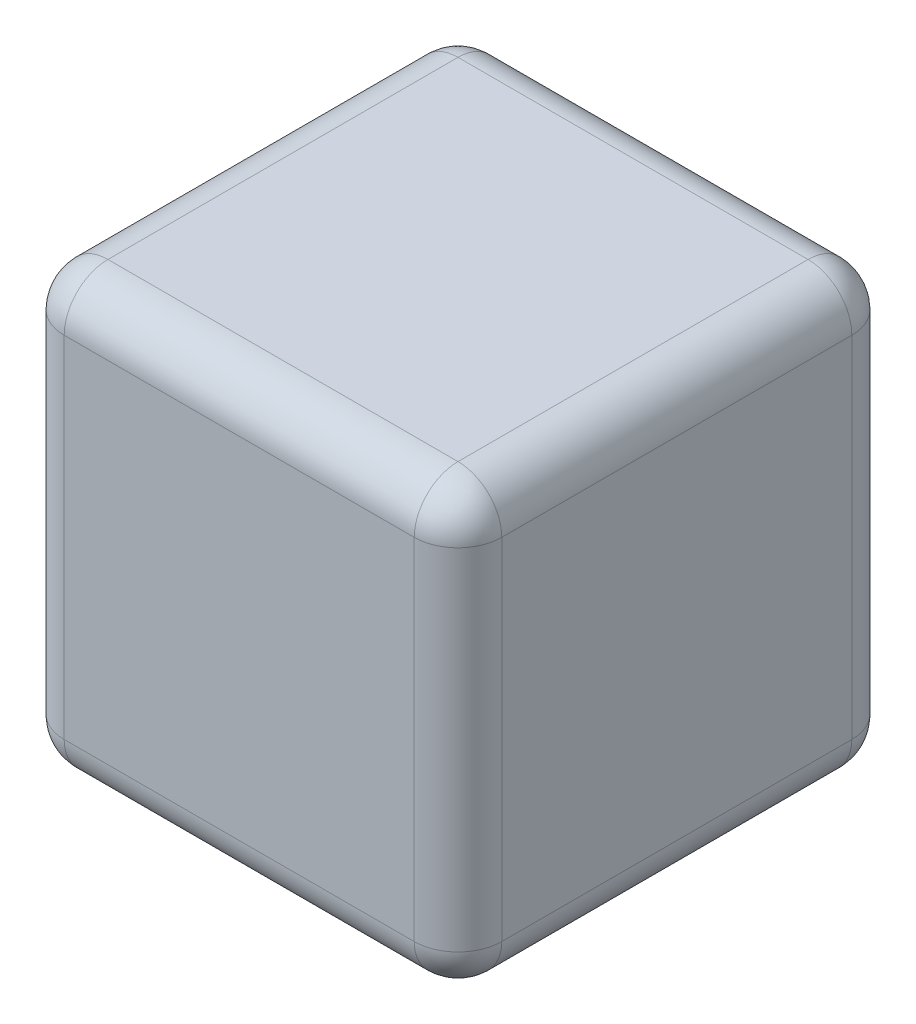
from build123d import *

# Parameters (mm, degrees)
SKETCH1_W           = 25.4
SKETCH1_H           = 25.4
BOSS_EXTRUDE1_DEPTH = 25.4
FILLET1_R           = 2.54


with BuildPart() as part:
    # Sketch1 → Boss-Extrude1 (new body)
    with BuildSketch(Plane(origin=(0, 0, 0), x_dir=(1, 0, 0), z_dir=(0, 1, 0))):
        with Locations((12.7, 12.7)):
            Rectangle(SKETCH1_W, SKETCH1_H)
    extrude(amount=BOSS_EXTRUDE1_DEPTH)

    # Fillet1
    fillet1_edges = [part.edges().sort_by_distance(p)[0] for p in [
        (12.7, 25.4, -25.4),
        (0, 25.4, -12.7),
        (12.7, 25.4, 0),
        (0, 0, -12.7),
        (12.7, 0, -25.4),
        (25.4, 0, -12.7),
        (12.7, 0, 0),
        (0, 12.7, 0),
        (0, 12.7, -25.4),
        (25.4, 12.7, -25.4),
        (25.4, 12.7, 0),
        (25.4, 25.4, -12.7),
    ]]
    fillet(fillet1_edges, radius=FILLET1_R)


solid = part.part
